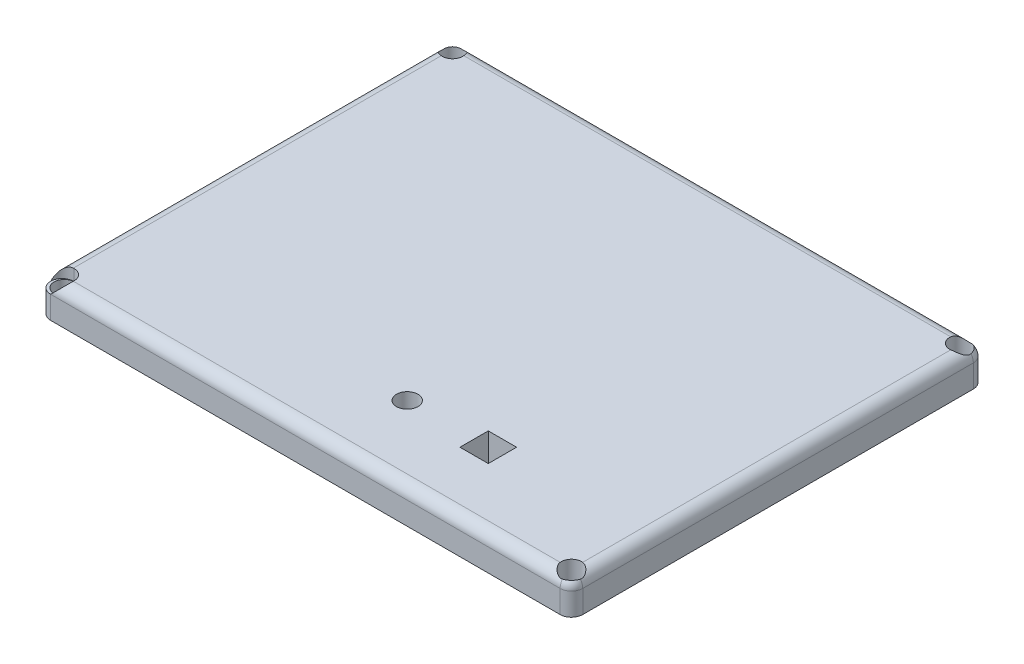
from build123d import *

# Parameters (mm, degrees)
SKETCH1_W           = 119.38
SKETCH1_H           = 92.71
BOSS_EXTRUDE1_DEPTH = 7.62
FILLET1_R           = 2.54
SKETCH3_R           = 2.413
CUT_EXTRUDE1_DEPTH  = 8.128
SKETCH4_W           = 6.35
SKETCH4_H           = 6.35
CUT_EXTRUDE2_DEPTH  = 7.62
SKETCH5_R           = 2.54
CUT_EXTRUDE3_DEPTH  = 2.54
SKETCH6_W           = 109.728
SKETCH6_H           = 83.058
SKETCH6_W_2         = 104.648
SKETCH6_H_2         = 77.978
BOSS_EXTRUDE2_DEPTH = 2.54
SKETCH8_R           = 2.286
CUT_EXTRUDE4_DEPTH  = 8.62
SKETCH9_R           = 2.286
CUT_EXTRUDE5_DEPTH  = 8.6200001
SKETCH11_R          = 2.286
CUT_EXTRUDE6_DEPTH  = 8.6200001
SKETCH12_R          = 2.286
CUT_EXTRUDE7_DEPTH  = 8.6200001


with BuildPart() as part:
    # Sketch1 → Boss-Extrude1 (new body)
    with BuildSketch(Plane(origin=(0, 0, 0), x_dir=(1, 0, 0), z_dir=(0, 1, 0))):
        Rectangle(SKETCH1_W, SKETCH1_H)
    extrude(amount=BOSS_EXTRUDE1_DEPTH)

    # Fillet1
    fillet1_edges = [part.edges().sort_by_distance(p)[0] for p in [
        (-59.69, 7.62, 0),
        (0, 7.62, 46.355),
        (59.69, 7.62, 0),
        (0, 7.62, -46.355),
        (59.69, 3.81, 46.355),
        (-59.69, 3.81, 46.355),
        (-59.69, 3.81, -46.355),
        (59.69, 3.81, -46.355),
    ]]
    fillet(fillet1_edges, radius=FILLET1_R)

    # Sketch3 → Cut-Extrude1 (cut)
    with BuildSketch(Plane.XZ):
        with Locations((6.008676456, 29.518648142)):
            Circle(SKETCH3_R)
    extrude(amount=-CUT_EXTRUDE1_DEPTH, mode=Mode.SUBTRACT)

    # Sketch4 → Cut-Extrude2 (cut)
    with BuildSketch(Plane.XZ):
        with Locations((24.193347407, 29.518339929)):
            Rectangle(SKETCH4_W, SKETCH4_H)
    extrude(amount=-CUT_EXTRUDE2_DEPTH, mode=Mode.SUBTRACT)

    # Sketch5 → Cut-Extrude3 (cut)
    with BuildSketch(Plane(origin=(0, 7.62, 0), x_dir=(1, 0, 0), z_dir=(0, 1, 0))):
        with Locations((-57.15, -43.815)):
            Circle(SKETCH5_R)
    extrude(amount=-CUT_EXTRUDE3_DEPTH, mode=Mode.SUBTRACT)

    # Sketch6 → Boss-Extrude2 (add)
    with BuildSketch(Plane(origin=(0, 0, 0), x_dir=(-1, 0, 0), z_dir=(0, -1, 0))):
        Rectangle(SKETCH6_W, SKETCH6_H)
        Rectangle(SKETCH6_W_2, SKETCH6_H_2, mode=Mode.SUBTRACT)
    extrude(amount=BOSS_EXTRUDE2_DEPTH)

    # Sketch8 → Cut-Extrude4 (cut, through all)
    with BuildSketch(Plane.XZ):
        with Locations((56.896, 43.561)):
            Circle(SKETCH8_R)
    extrude(amount=-CUT_EXTRUDE4_DEPTH, mode=Mode.SUBTRACT)

    # Sketch9 → Cut-Extrude5 (cut, through all)
    with BuildSketch(Plane(origin=(0, 0, 0), x_dir=(-1, 0, 0), z_dir=(0, -1, 0))):
        with Locations((-56.896, 43.561)):
            Circle(SKETCH9_R)
    extrude(amount=-CUT_EXTRUDE5_DEPTH, mode=Mode.SUBTRACT)

    # Sketch11 → Cut-Extrude6 (cut, through all)
    with BuildSketch(Plane.XZ):
        with Locations((-56.896, -43.561)):
            Circle(SKETCH11_R)
    extrude(amount=-CUT_EXTRUDE6_DEPTH, mode=Mode.SUBTRACT)

    # Sketch12 → Cut-Extrude7 (cut, through all)
    with BuildSketch(Plane.XZ):
        with Locations((-56.896, 43.561)):
            Circle(SKETCH12_R)
    extrude(amount=-CUT_EXTRUDE7_DEPTH, mode=Mode.SUBTRACT)


solid = part.part
